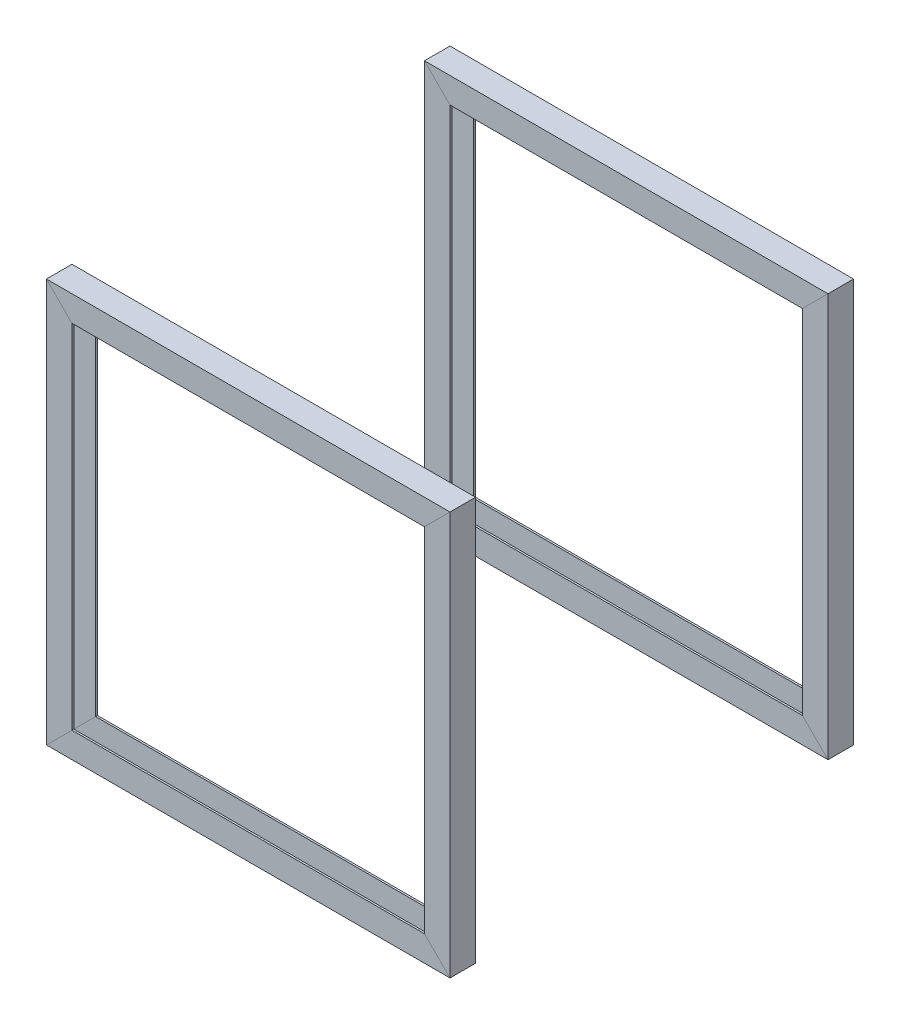
from build123d import *

# Parameters (mm, degrees)
C_CHANNEL_80_X_8_1_DEPTH      = 164.435028843
C_CHANNEL_80_X_8_1_DEPTH_BACK = 14.435028843
C_CHANNEL_80_X_8_1_2_DEPTH    = 178.870057685
C_CHANNEL_80_X_8_1_3_DEPTH    = 178.870057685
C_CHANNEL_80_X_8_1_4_DEPTH    = 178.870057685


with BuildPart() as part:
    # Sketch11 → C channel 80 X 8(1) (new, two sides)
    with BuildSketch(Plane(origin=(-75, 75, 0), x_dir=(0, 1, 0), z_dir=(1, 0, 0))) as c_channel_80_x_8_1_sk:
        Polygon((0, 0), (0, -9.5), (-9.5, -9.5), (-9.5, -8.8), (-0.7, -8.8), (-0.7, -0.7), (-9.5, -0.7), (-9.5, 0), align=None)
    extrude(amount=C_CHANNEL_80_X_8_1_DEPTH)
    extrude(c_channel_80_x_8_1_sk.sketch, amount=-C_CHANNEL_80_X_8_1_DEPTH_BACK)

    # C channel 80 X 8(1) mitre 1
    split(bisect_by=Plane(origin=(-75, 75, 0), x_dir=(-0.707106781, 0.707106781, 0), z_dir=(0.707106781, 0.707106781, 0)), keep=Keep.TOP)

    # C channel 80 X 8(1) mitre 2
    split(bisect_by=Plane(origin=(75, 75, 0), x_dir=(-0.707106781, -0.707106781, 0), z_dir=(-0.707106781, 0.707106781, 0)), keep=Keep.TOP)


with BuildPart() as body_2:
    # Sketch11 on segment 2 (carried to segment 2) → C channel 80 X 8_1 2 (new body)
    with BuildSketch(Plane(origin=(75, 89.435028843, 0), x_dir=(1, 0, 0), z_dir=(0, -1, 0))):
        Polygon((0, 0), (0, -9.5), (-9.5, -9.5), (-9.5, -8.8), (-0.7, -8.8), (-0.7, -0.7), (-9.5, -0.7), (-9.5, 0), align=None)
    extrude(amount=C_CHANNEL_80_X_8_1_2_DEPTH)

    # C channel 80 X 8_1 2 mitre 1
    split(bisect_by=Plane(origin=(75, 75, 0), x_dir=(0.707106781, 0.707106781, 0), z_dir=(0.707106781, -0.707106781, 0)), keep=Keep.TOP)

    # C channel 80 X 8_1 2 mitre 2
    split(bisect_by=Plane(origin=(75, -75, 0), x_dir=(-0.707106781, 0.707106781, 0), z_dir=(0.707106781, 0.707106781, 0)), keep=Keep.TOP)


with BuildPart() as body_3:
    # Sketch11 on segment 3 (carried to segment 3) → C channel 80 X 8_1 3 (new body)
    with BuildSketch(Plane(origin=(89.435028843, -75, 0), x_dir=(0, -1, 0), z_dir=(-1, 0, 0))):
        Polygon((0, 0), (0, -9.5), (-9.5, -9.5), (-9.5, -8.8), (-0.7, -8.8), (-0.7, -0.7), (-9.5, -0.7), (-9.5, 0), align=None)
    extrude(amount=C_CHANNEL_80_X_8_1_3_DEPTH)

    # C channel 80 X 8_1 3 mitre 1
    split(bisect_by=Plane(origin=(-75, -75, 0), x_dir=(0.707106781, 0.707106781, 0), z_dir=(0.707106781, -0.707106781, 0)), keep=Keep.TOP)

    # C channel 80 X 8_1 3 mitre 2
    split(bisect_by=Plane(origin=(75, -75, 0), x_dir=(0.707106781, -0.707106781, 0), z_dir=(-0.707106781, -0.707106781, 0)), keep=Keep.TOP)


with BuildPart() as body_4:
    # Sketch11 on segment 4 (carried to segment 4) → C channel 80 X 8_1 4 (new body)
    with BuildSketch(Plane(origin=(-75, -89.435028843, 0), x_dir=(-1, 0, 0), z_dir=(0, 1, 0))):
        Polygon((0, 0), (0, -9.5), (-9.5, -9.5), (-9.5, -8.8), (-0.7, -8.8), (-0.7, -0.7), (-9.5, -0.7), (-9.5, 0), align=None)
    extrude(amount=C_CHANNEL_80_X_8_1_4_DEPTH)

    # C channel 80 X 8_1 4 mitre 1
    split(bisect_by=Plane(origin=(-75, 75, 0), x_dir=(0.707106781, -0.707106781, 0), z_dir=(-0.707106781, -0.707106781, 0)), keep=Keep.TOP)

    # C channel 80 X 8_1 4 mitre 2
    split(bisect_by=Plane(origin=(-75, -75, 0), x_dir=(-0.707106781, -0.707106781, 0), z_dir=(-0.707106781, 0.707106781, 0)), keep=Keep.TOP)


with BuildPart() as body_5:
    # Mirror1: mirrored copy
    add(body_3.part.mirror(Plane.XY.offset(-75)))


with BuildPart() as body_6:
    # Mirror1 2: mirrored copy
    add(body_4.part.mirror(Plane.XY.offset(-75)))


with BuildPart() as body_7:
    # Mirror1 3: mirrored copy
    add(body_2.part.mirror(Plane.XY.offset(-75)))


with BuildPart() as body_8:
    # Mirror1 4: mirrored copy
    add(part.part.mirror(Plane.XY.offset(-75)))


solid = Compound([part.part, body_2.part, body_3.part, body_4.part, body_5.part, body_6.part, body_7.part, body_8.part])
